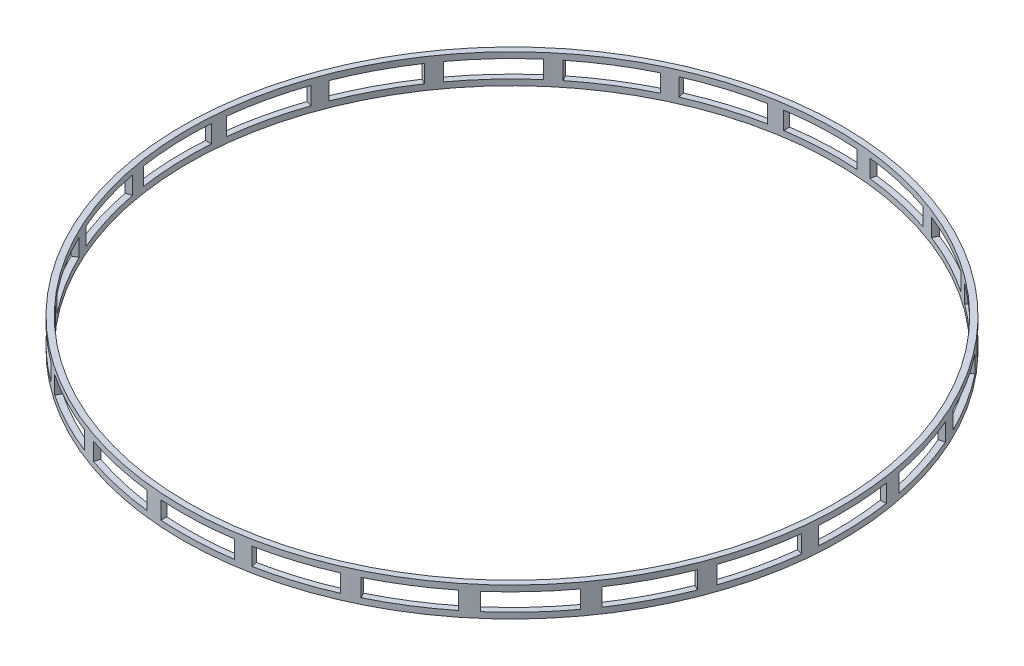
from build123d import *

# Parameters (mm, degrees)
SKETCH1_R           = 112
SKETCH1_R_2         = 110
BOSS_EXTRUDE1_DEPTH = 10
SKETCH2_W           = 24
SKETCH2_H           = 6
CUT_EXTRUDE1_DEPTH  = 159.707277716
CIRPATTERN1_COUNT   = 24


with BuildPart() as part:
    # Sketch1 → Boss-Extrude1 (new body)
    with BuildSketch(Plane(origin=(0, 0, 0), x_dir=(1, 0, 0), z_dir=(0, 1, 0))):
        Circle(SKETCH1_R)
        Circle(SKETCH1_R_2, mode=Mode.SUBTRACT)
    extrude(amount=BOSS_EXTRUDE1_DEPTH)

    # Sketch2 → Cut-Extrude1 (cut, through all)
    with BuildSketch(Plane.XY):
        with Locations((-4.41590823, 5)):
            Rectangle(SKETCH2_W, SKETCH2_H)
    cut_extrude1 = extrude(amount=-CUT_EXTRUDE1_DEPTH, mode=Mode.SUBTRACT)

    # CirPattern1: Cut-Extrude1 ×24 about axis
    cirpattern1_axis = Axis((0, 10, 0), (0, -1, 0))
    for i in range(1, CIRPATTERN1_COUNT):
        add(cut_extrude1.rotate(cirpattern1_axis, i * 360 / CIRPATTERN1_COUNT), mode=Mode.SUBTRACT)


solid = part.part
